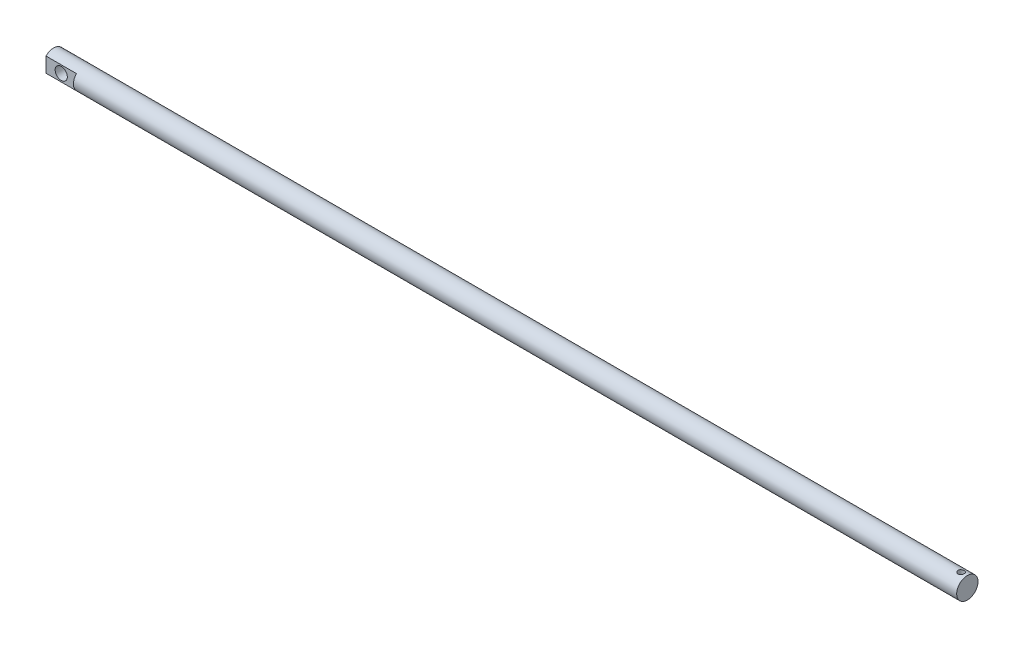
from build123d import *

# Parameters (mm, degrees)
SKETCH_1_R           = 7
EXTRUDE_1_DEPTH      = 600
SKETCH_3_OUTSIDE_W   = 136.066
SKETCH_3_OUTSIDE_H   = 136.066
SKETCH_3_OUTSIDE_W_2 = 10
SKETCH_3_OUTSIDE_H_2 = 20
CUT_EXTRUDE_1_DEPTH  = 20
SKETCH_4_R           = 4
CUT_EXTRUDE_3_DEPTH  = 20
SKETCH_5_R           = 2
CUT_EXTRUDE_4_DEPTH  = 15


with BuildPart() as part:
    # 草图1 → 凸台-拉伸1 (new body)
    with BuildSketch(Plane(origin=(0, 0, 0), x_dir=(0, 0, -1), z_dir=(1, 0, 0))):
        Circle(SKETCH_1_R)
    extrude(amount=EXTRUDE_1_DEPTH)

    # 草图3 outside → 切除-拉伸1 (cut)
    with BuildSketch(Plane.ZY):
        Rectangle(SKETCH_3_OUTSIDE_W, SKETCH_3_OUTSIDE_H)
        Rectangle(SKETCH_3_OUTSIDE_W_2, SKETCH_3_OUTSIDE_H_2, mode=Mode.SUBTRACT)
    extrude(amount=-CUT_EXTRUDE_1_DEPTH, mode=Mode.SUBTRACT)

    # 草图4 → 切除-拉伸3 (cut)
    with BuildSketch(Plane(origin=(0, 0, -5), x_dir=(-1, 0, 0), z_dir=(0, 0, -1))):
        with Locations((-10, 0)):
            Circle(SKETCH_4_R)
    extrude(amount=-CUT_EXTRUDE_3_DEPTH, mode=Mode.SUBTRACT)

    # 草图5 → 切除-拉伸4 (cut, through all)
    with BuildSketch(Plane(origin=(-583.138159927, 7, 1388.026133711), x_dir=(-1, 0, 0), z_dir=(0, 1, 0))):
        with Locations((-1179.138160513, -1388.026133214)):
            Circle(SKETCH_5_R)
    extrude(amount=-CUT_EXTRUDE_4_DEPTH, mode=Mode.SUBTRACT)


solid = part.part
